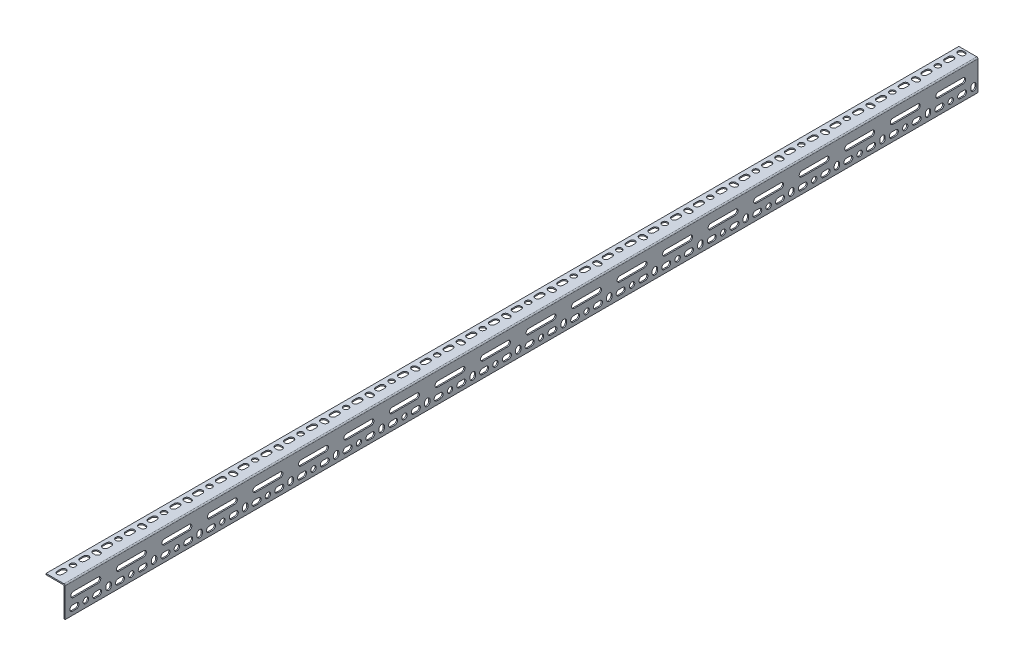
from build123d import *

# Parameters (mm, degrees)
STRUCTURAL_MEMBER1_DEPTH     = 1524
SLOT_1_5_DEPTH               = 1526.182166169
SKETCH13_R                   = 4.5
HOLE_1_5_DEPTH               = 1526.182166169
VERTICAL_SLOT_1_5_DEPTH      = 1526.182166169
SMALL_SLOT_2_5_DEPTH         = 1526.182166169
SKETCH16_R                   = 4.5
HOLE_2_5_DEPTH               = 1526.182166169
VERTICAL_SLOT_2_5_DEPTH      = 1526.182166169
LONG_SLOT_2_5_DEPTH          = 1526.182166169
SHORT_SLOT_PATTERN_1_5_COUNT = 40
SHORT_SLOT_PATTERN_1_5_PITCH = 38
HOLE_PATTERN_COUNT           = 20
HOLE_PATTERN_PITCH           = 76
VERT_SLOT_PATTERN_COUNT      = 20
VERT_SLOT_PATTERN_PITCH      = 76
LONG_SLOT_PATTERN_COUNT      = 20
LONG_SLOT_PATTERN_PITCH      = 76


with BuildPart() as part:
    # Sketch112 → Structural Member1 (new body)
    with BuildSketch(Plane(origin=(0, 0, 0), x_dir=(-1, 0, 0), z_dir=(0, 0, 1))):
        with BuildLine():
            Line((0, 2), (0, 50.8))
            Line((0, 50.8), (1, 50.8))
            ThreePointArc((1, 50.8), (1.707106781, 50.507106781), (2, 49.8))
            Line((2, 49.8), (2, 4))
            ThreePointArc((2, 4), (2.585786438, 2.585786438), (4, 2))
            Line((4, 2), (31, 2))
            ThreePointArc((31, 2), (31.707106781, 1.707106781), (32, 1))
            Line((32, 1), (32, 0))
            Line((32, 0), (2, 0))
            ThreePointArc((2, 0), (0.585786438, 0.585786438), (0, 2))
        make_face()
    extrude(amount=-STRUCTURAL_MEMBER1_DEPTH)

    # Sketch12 → Slot 1.5 (cut, through all)
    with BuildSketch(Plane(origin=(0, 0, 0), x_dir=(1, 0, 0), z_dir=(0, 1, 0))):
        with BuildLine():
            Line((-26, 12.5), (-26, 18.5))
            ThreePointArc((-26, 18.5), (-21.5, 23), (-17, 18.5))
            Line((-17, 18.5), (-17, 12.5))
            ThreePointArc((-17, 12.5), (-21.5, 8), (-26, 12.5))
        make_face()
    slot_1_5 = extrude(amount=-SLOT_1_5_DEPTH, mode=Mode.SUBTRACT)

    # Sketch13 → Hole 1.5 (cut, through all)
    with BuildSketch(Plane(origin=(0, 0, 0), x_dir=(1, 0, 0), z_dir=(0, 1, 0))):
        with Locations(Location((-21.5, 34.5, 0), (0, 0, 180))):
            Circle(SKETCH13_R)
    hole_1_5 = extrude(amount=-HOLE_1_5_DEPTH, mode=Mode.SUBTRACT)

    # Sketch18 → Vertical Slot 1.5 (cut, through all)
    with BuildSketch(Plane(origin=(0, 0, 0), x_dir=(1, 0, 0), z_dir=(0, 1, 0))):
        with BuildLine():
            Line((-21.5, 77), (-18.5, 77))
            ThreePointArc((-18.5, 77), (-14, 72.5), (-18.5, 68))
            Line((-18.5, 68), (-21.5, 68))
            ThreePointArc((-21.5, 68), (-26, 72.5), (-21.5, 77))
        make_face()
    vertical_slot_1_5 = extrude(amount=-VERTICAL_SLOT_1_5_DEPTH, mode=Mode.SUBTRACT)

    # Sketch15 → Small Slot 2.5 (cut, through all)
    with BuildSketch(Plane(origin=(0, 0, 0), x_dir=(0, 0, -1), z_dir=(1, 0, 0))):
        with BuildLine():
            Line((12.5, -35.8), (18.5, -35.8))
            ThreePointArc((18.5, -35.8), (23, -40.3), (18.5, -44.8))
            Line((18.5, -44.8), (12.5, -44.8))
            ThreePointArc((12.5, -44.8), (8, -40.3), (12.5, -35.8))
        make_face()
    small_slot_2_5 = extrude(amount=-SMALL_SLOT_2_5_DEPTH, mode=Mode.SUBTRACT)

    # Sketch16 → Hole 2.5 (cut, through all)
    with BuildSketch(Plane(origin=(0, 0, 0), x_dir=(0, 0, -1), z_dir=(1, 0, 0))):
        with Locations((34.5, -40.3)):
            Circle(SKETCH16_R)
    hole_2_5 = extrude(amount=-HOLE_2_5_DEPTH, mode=Mode.SUBTRACT)

    # Sketch17 → Vertical Slot 2.5 (cut, through all)
    with BuildSketch(Plane(origin=(0, 0, 0), x_dir=(0, 0, -1), z_dir=(1, 0, 0))):
        with BuildLine():
            Line((77, -37.3), (77, -40.3))
            ThreePointArc((77, -40.3), (72.5, -44.8), (68, -40.3))
            Line((68, -40.3), (68, -37.3))
            ThreePointArc((68, -37.3), (72.5, -32.8), (77, -37.3))
        make_face()
    vertical_slot_2_5 = extrude(amount=-VERTICAL_SLOT_2_5_DEPTH, mode=Mode.SUBTRACT)

    # Sketch14 → Long Slot 2.5 (cut, through all)
    with BuildSketch(Plane(origin=(0, 0, 0), x_dir=(0, 0, -1), z_dir=(1, 0, 0))):
        with BuildLine():
            Line((14, -16.75), (55, -16.75))
            ThreePointArc((55, -16.75), (59.5, -21.25), (55, -25.75))
            Line((55, -25.75), (14, -25.75))
            ThreePointArc((14, -25.75), (9.5, -21.25), (14, -16.75))
        make_face()
    long_slot_2_5 = extrude(amount=-LONG_SLOT_2_5_DEPTH, mode=Mode.SUBTRACT)

    # Short Slot pattern 1.5: Slot 1.5, Small Slot 2.5 ×40
    with Locations(*[(0, 0, -i * SHORT_SLOT_PATTERN_1_5_PITCH) for i in range(1, SHORT_SLOT_PATTERN_1_5_COUNT)]):
        add(slot_1_5, mode=Mode.SUBTRACT)
        add(small_slot_2_5, mode=Mode.SUBTRACT)

    # Hole pattern: Hole 1.5, Hole 2.5 ×20
    with Locations(*[(0, 0, -i * HOLE_PATTERN_PITCH) for i in range(1, HOLE_PATTERN_COUNT)]):
        add(hole_1_5, mode=Mode.SUBTRACT)
        add(hole_2_5, mode=Mode.SUBTRACT)

    # Vert Slot Pattern: Vertical Slot 1.5, Vertical Slot 2.5 ×20
    with Locations(*[(0, 0, -i * VERT_SLOT_PATTERN_PITCH) for i in range(1, VERT_SLOT_PATTERN_COUNT)]):
        add(vertical_slot_1_5, mode=Mode.SUBTRACT)
        add(vertical_slot_2_5, mode=Mode.SUBTRACT)

    # Long Slot pattern: Long Slot 2.5 ×20
    with Locations(*[(0, 0, -i * LONG_SLOT_PATTERN_PITCH) for i in range(1, LONG_SLOT_PATTERN_COUNT)]):
        add(long_slot_2_5, mode=Mode.SUBTRACT)


solid = part.part
